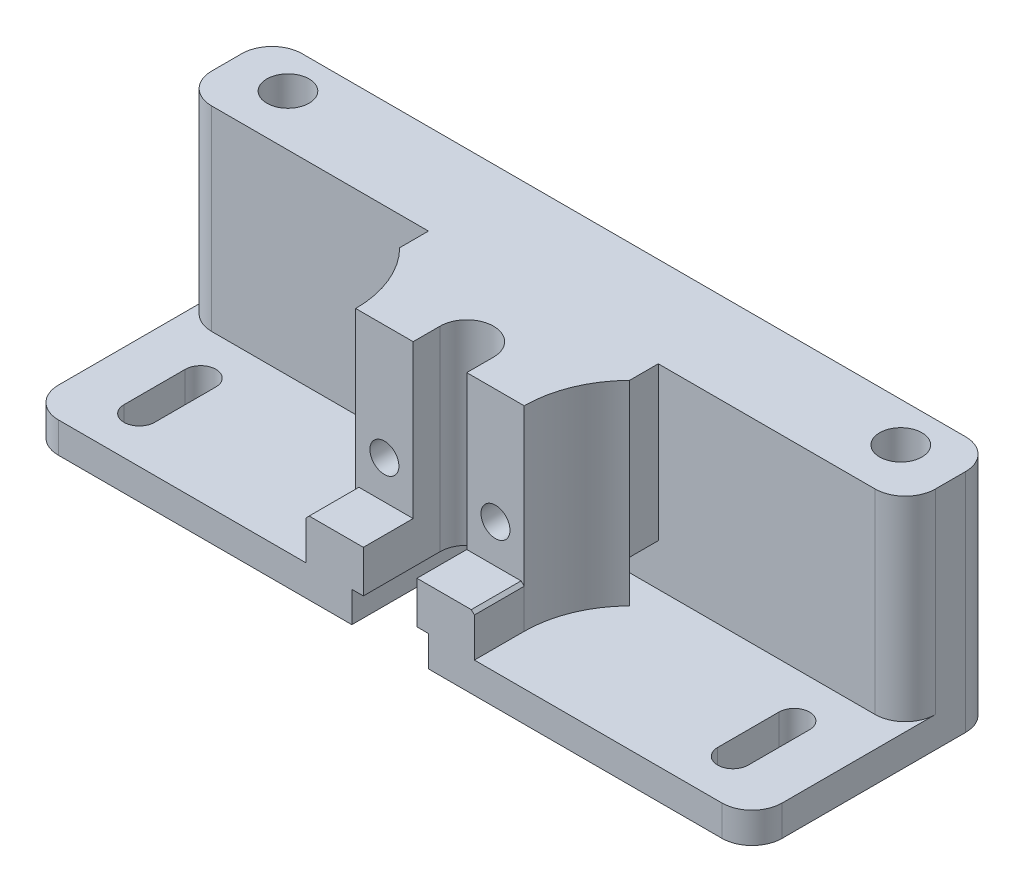
from build123d import *

# Parameters (mm, degrees)
SKETCH1_W                  = 38.1
SKETCH1_H                  = 25.4
BOSS_EXTRUDE1_DEPTH        = 25.0825
CUT_EXTRUDE3_DEPTH         = 26.4
CUT_EXTRUDE4_DEPTH         = 26.4
CUT_EXTRUDE5_DEPTH         = 26.4
BOSS_EXTRUDE2_DEPTH        = 6.985
BOSS_EXTRUDE3_DEPTH        = 5.08
SKETCH29_W                 = 19.05
SKETCH29_H                 = 5.08
CUT_EXTRUDE6_DEPTH         = 1.905
SKETCH30_W                 = 19.05
SKETCH30_H                 = 5.08
CUT_EXTRUDE7_DEPTH         = 1.905
CUT_EXTRUDE10_REACH        = 39.465
CUT_EXTRUDE11_REACH        = 39.465
SKETCH77_W                 = 1.4732
SKETCH77_H                 = 16.0274
M2_5_CLEARANCE_HOLE1_D     = 2.9464
M2_5_CLEARANCE_HOLE1_DEPTH = 25.0825
CHAMFER1_SIZE              = 0.511100582
CHAMFER1_SIZE2             = 0.522104304
CHAMFER2_SIZE              = 0.558247665
CHAMFER2_SIZE2             = 0.538663646
SKETCH80_W                 = 38.1
SKETCH80_H                 = 25.4
CUT_EXTRUDE13_DEPTH        = 7.9375
SKETCH81_W                 = 120
SKETCH81_H                 = 15
BOSS_EXTRUDE4_DEPTH        = 37.465
SKETCH82_R                 = 3.5
CUT_EXTRUDE14_DEPTH        = 38.465
FILLET3_R                  = 5
FILLET4_R                  = 5
FILLET5_R                  = 5
SKETCH83_R                 = 2.4003
CUT_EXTRUDE15_DEPTH        = 7.1374


with BuildPart() as part:
    # Sketch1 → Boss-Extrude1 (new body)
    with BuildSketch(Plane(origin=(0, 0, -20.6375), x_dir=(-1, 0, 0), z_dir=(0, 0, -1))):
        with Locations((0, 12.7)):
            Rectangle(SKETCH1_W, SKETCH1_H)
    extrude(amount=-BOSS_EXTRUDE1_DEPTH)

    # Sketch18 → Cut-Extrude3 (cut, through all)
    with BuildSketch(Plane(origin=(0, 0, 0), x_dir=(-1, 0, 0), z_dir=(0, -1, 0))):
        with BuildLine():
            Line((13.97, -4.445), (19.05, -4.445))
            Line((19.05, -4.445), (19.05, 7.9375))
            ThreePointArc((19.05, 7.9375), (15.289364951, 2.247023353), (13.97, -4.445))
        make_face()
    extrude(amount=-CUT_EXTRUDE3_DEPTH, mode=Mode.SUBTRACT)

    # Sketch19 → Cut-Extrude4 (cut, through all)
    with BuildSketch(Plane.XZ):
        with BuildLine():
            Line((4.445, 4.445), (-4.445, 4.445))
            Line((-4.445, 4.445), (-4.445, 0))
            ThreePointArc((-4.445, 0), (0, -4.445), (4.445, 0))
            Line((4.445, 0), (4.445, 4.445))
        make_face()
    extrude(amount=-CUT_EXTRUDE4_DEPTH, mode=Mode.SUBTRACT)

    # Sketch20 → Cut-Extrude5 (cut, through all)
    with BuildSketch(Plane.XZ):
        with BuildLine():
            Line((19.05, -7.9375), (19.05, 4.445))
            Line((19.05, 4.445), (13.97, 4.445))
            ThreePointArc((13.97, 4.445), (15.289364951, -2.247023353), (19.05, -7.9375))
        make_face()
    extrude(amount=-CUT_EXTRUDE5_DEPTH, mode=Mode.SUBTRACT)

    # Sketch21 → Boss-Extrude2 (add)
    with BuildSketch(Plane.XZ):
        with BuildLine():
            Line((4.445, 0), (4.445, 12.7))
            Line((4.445, 12.7), (13.97, 12.7))
            Line((13.97, 12.7), (13.97, 4.445))
            ThreePointArc((13.97, 4.445), (15.289364951, -2.247023353), (19.05, -7.9375))
            Line((19.05, -7.9375), (-19.05, -7.9375))
            ThreePointArc((-19.05, -7.9375), (-15.289364951, -2.247023353), (-13.97, 4.445))
            Line((-13.97, 4.445), (-13.97, 12.7))
            Line((-13.97, 12.7), (-4.445, 12.7))
            Line((-4.445, 12.7), (-4.445, 0))
            ThreePointArc((-4.445, 0), (0, -4.445), (4.445, 0))
        make_face()
    extrude(amount=BOSS_EXTRUDE2_DEPTH)

    # Sketch22 → Boss-Extrude3 (add)
    with BuildSketch(Plane.XZ.offset(6.985)):
        Polygon((-4.445, -6.35), (4.445, -6.35), (4.445, 12.7), (60, 12.7), (60, -12.7), (-60, -12.7), (-60, 12.7), (-4.445, 12.7), align=None)
    extrude(amount=BOSS_EXTRUDE3_DEPTH)

    # Sketch29 → Cut-Extrude6 (cut)
    with BuildSketch(Plane.ZY.offset(-4.445)):
        with Locations((3.175, -9.525)):
            Rectangle(SKETCH29_W, SKETCH29_H)
    extrude(amount=-CUT_EXTRUDE6_DEPTH, mode=Mode.SUBTRACT)

    # Sketch30 → Cut-Extrude7 (cut)
    with BuildSketch(Plane(origin=(-4.445, 0, 0), x_dir=(0, 0, -1), z_dir=(1, 0, 0))):
        with Locations((-3.175, -9.525)):
            Rectangle(SKETCH30_W, SKETCH30_H)
    extrude(amount=-CUT_EXTRUDE7_DEPTH, mode=Mode.SUBTRACT)

    # Sketch48 → Cut-Extrude10 (cut, up to next)
    with BuildSketch(Plane(origin=(0, -12.065, 0), x_dir=(-1, 0, 0), z_dir=(0, -1, 0)), mode=Mode.PRIVATE) as cut_extrude10_sk1:
        with BuildLine():
            Line((-51.7525, 5.08), (-51.7525, -5.08))
            ThreePointArc((-51.7525, -5.08), (-49.2125, -7.62), (-46.6725, -5.08))
            Line((-46.6725, -5.08), (-46.6725, 5.08))
            ThreePointArc((-46.6725, 5.08), (-49.2125, 7.62), (-51.7525, 5.08))
        make_face()
    cut_extrude10_tool1 = extrude(cut_extrude10_sk1.sketch, amount=-CUT_EXTRUDE10_REACH, mode=Mode.PRIVATE) & part.part
    add(cut_extrude10_tool1.solids().sort_by_distance((49.2125, -12.065, 0))[0], mode=Mode.SUBTRACT)

    # Sketch57 → Cut-Extrude11 (cut, up to next)
    with BuildSketch(Plane(origin=(0, -12.065, 0), x_dir=(-1, 0, 0), z_dir=(0, -1, 0)), mode=Mode.PRIVATE) as cut_extrude11_sk1:
        with BuildLine():
            Line((46.6725, 5.08), (46.6725, -5.08))
            ThreePointArc((46.6725, -5.08), (49.2125, -7.62), (51.7525, -5.08))
            Line((51.7525, -5.08), (51.7525, 5.08))
            ThreePointArc((51.7525, 5.08), (49.2125, 7.62), (46.6725, 5.08))
        make_face()
    cut_extrude11_tool1 = extrude(cut_extrude11_sk1.sketch, amount=-CUT_EXTRUDE11_REACH, mode=Mode.PRIVATE) & part.part
    add(cut_extrude11_tool1.solids().sort_by_distance((-49.2125, -12.065, 0))[0], mode=Mode.SUBTRACT)

    # Sketch77 → Cut-Revolve2 (revolve, cut)
    with BuildSketch(Plane(origin=(0, 6.35, 0), x_dir=(1, 0, 0), z_dir=(0, 1, 0))):
        with Locations((9.9441, 12.6238)):
            Rectangle(SKETCH77_W, SKETCH77_H)
    revolve(axis=Axis((9.2075, 6.35, -20.6375), (0, 0, 1)), mode=Mode.SUBTRACT)

    # M2.5 Clearance Hole1
    with Locations(Plane.XY.offset(4.445)):
        with Locations((9.2075, 6.35), (-9.2075, 6.35)):
            Hole(M2_5_CLEARANCE_HOLE1_D / 2, depth=M2_5_CLEARANCE_HOLE1_DEPTH)

    # Chamfer1
    chamfer1_edges = [part.edges().sort_by_distance(p)[0] for p in [
        (13.97, 0, 8.5725),
    ]]
    chamfer1_side = [part.faces().sort_by_distance(p)[0] for p in [
        (13.97, -3.4925, 8.5725),
    ]]
    chamfer(chamfer1_edges, length=CHAMFER1_SIZE, length2=CHAMFER1_SIZE2, reference=chamfer1_side[0])

    # Chamfer2
    chamfer2_edges = [part.edges().sort_by_distance(p)[0] for p in [
        (-13.97, 0, 8.5725),
    ]]
    chamfer2_side = [part.faces().sort_by_distance(p)[0] for p in [
        (-13.97, -3.4925, 8.5725),
    ]]
    chamfer(chamfer2_edges, length=CHAMFER2_SIZE, length2=CHAMFER2_SIZE2, reference=chamfer2_side[0])

    # Sketch80 → Cut-Extrude13 (cut)
    with BuildSketch(Plane(origin=(0, 0, -20.6375), x_dir=(-1, 0, 0), z_dir=(0, 0, -1))):
        with Locations((0, 12.7)):
            Rectangle(SKETCH80_W, SKETCH80_H)
    extrude(amount=-CUT_EXTRUDE13_DEPTH, mode=Mode.SUBTRACT)

    # Sketch81 → Boss-Extrude4 (add)
    with BuildSketch(Plane(origin=(0, 25.4, 0), x_dir=(1, 0, 0), z_dir=(0, 1, 0))):
        with Locations((0, 20.2)):
            Rectangle(SKETCH81_W, SKETCH81_H)
    extrude(amount=-BOSS_EXTRUDE4_DEPTH)

    # Sketch82 → Cut-Extrude14 (cut, through all)
    with BuildSketch(Plane.XZ.offset(12.065)):
        with Locations((-50.8, -21.156433146)):
            Circle(SKETCH82_R)
        with Locations((50.8, -21.156433146)):
            Circle(SKETCH82_R)
    extrude(amount=-CUT_EXTRUDE14_DEPTH, mode=Mode.SUBTRACT)

    # Fillet3
    fillet3_edges = [part.edges().sort_by_distance(p)[0] for p in [
        (60, 6.6675, -27.7),
        (-60, 6.6675, -27.7),
    ]]
    fillet(fillet3_edges, radius=FILLET3_R)

    # Fillet4
    fillet4_edges = [part.edges().sort_by_distance(p)[0] for p in [
        (60, 9.2075, -12.7),
        (-60, 9.2075, -12.7),
    ]]
    fillet(fillet4_edges, radius=FILLET4_R)

    # Fillet5
    fillet5_edges = [part.edges().sort_by_distance(p)[0] for p in [
        (-60, -9.525, 12.7),
        (60, -9.525, 12.7),
    ]]
    fillet(fillet5_edges, radius=FILLET5_R)

    # Sketch83 → Cut-Extrude15 (cut)
    with BuildSketch(Plane.XY.offset(4.445)):
        with Locations((-9.2075, 6.35)):
            Circle(SKETCH83_R)
        with Locations((9.2075, 6.35)):
            Circle(SKETCH83_R)
    extrude(amount=-CUT_EXTRUDE15_DEPTH, mode=Mode.SUBTRACT)


solid = part.part
